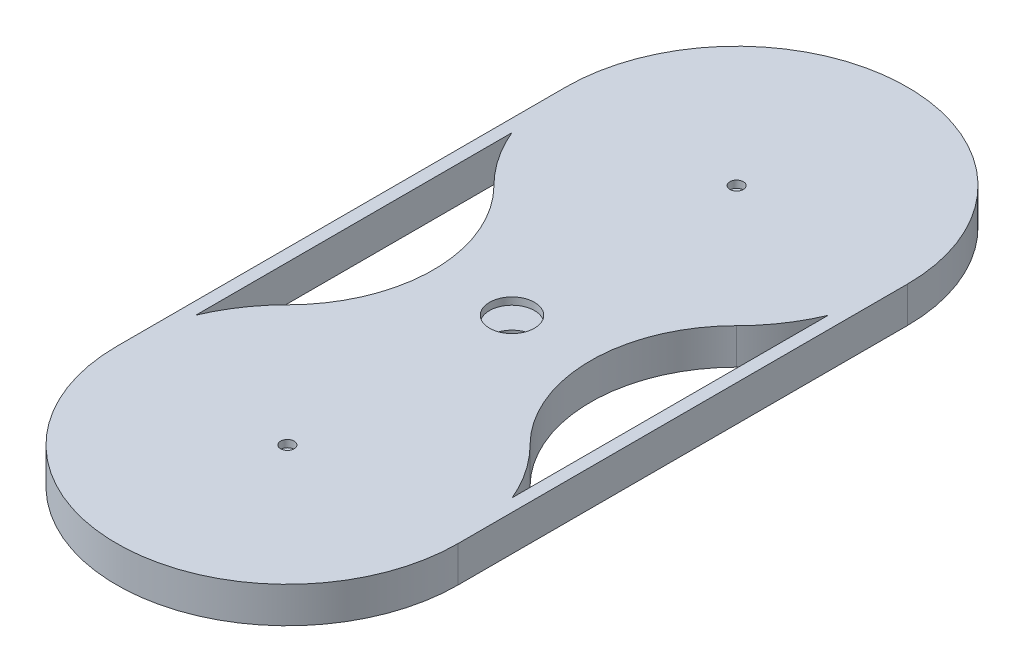
from build123d import *

# Parameters (mm, degrees)
BOSS_EXTRUDE1_DEPTH      = 2
BOSS_EXTRUDE1_DEPTH_BACK = 2
CUT_EXTRUDE1_DEPTH       = 1.2
CUT_EXTRUDE1_DEPTH_BACK  = 1.2
SKETCH4_W                = 7
SKETCH4_H                = 11
BOSS_EXTRUDE2_DEPTH      = 1.2
SWEEP1_PROFILE_R         = 1
SKETCH25_R               = 2.2
CUT_EXTRUDE2_DEPTH       = 2.2
SKETCH26_R               = 2.5
SKETCH26_R_2             = 0.75
CUT_EXTRUDE3_DEPTH       = 10.2
CUT_EXTRUDE4_DEPTH       = 10
CUT_EXTRUDE4_DEPTH_BACK  = 10


with BuildPart() as part:
    # Sketch1 → Boss-Extrude1 (new, two sides: drawn at the far end of the back side and taken through both)
    with BuildSketch(Plane(origin=(0, 0, 0), x_dir=(1, 0, 0), z_dir=(0, 1, 0)).offset(-BOSS_EXTRUDE1_DEPTH_BACK)):
        with BuildLine():
            Line((-19, 0), (-19, -50))
            ThreePointArc((-19, -50), (0, -69), (19, -50))
            Line((19, -50), (19, 0))
            ThreePointArc((19, 0), (0, 19), (-19, 0))
        make_face()
    extrude(amount=BOSS_EXTRUDE1_DEPTH + BOSS_EXTRUDE1_DEPTH_BACK)

    # Sketch3 → Cut-Extrude1 (cut, two sides: drawn at the far end of the back side and taken through both)
    with BuildSketch(Plane(origin=(0, 0, 0), x_dir=(1, 0, 0), z_dir=(0, 1, 0)).offset(-CUT_EXTRUDE1_DEPTH_BACK)):
        with BuildLine():
            ThreePointArc((12.445079349, -37.554920651), (7.244660941, -25), (12.445079349, -12.445079349))
            ThreePointArc((12.445079349, -12.445079349), (16.260279772, -6.73522841), (17.6, 0))
            ThreePointArc((17.6, 0), (0, 17.6), (-17.6, 0))
            ThreePointArc((-17.6, 0), (-16.260279772, -6.73522841), (-12.445079349, -12.445079349))
            ThreePointArc((-12.445079349, -12.445079349), (-7.244660941, -25), (-12.445079349, -37.554920651))
            ThreePointArc((-12.445079349, -37.554920651), (-16.260279772, -43.26477159), (-17.6, -50))
            ThreePointArc((-17.6, -50), (0, -67.6), (17.6, -50))
            ThreePointArc((17.6, -50), (16.260279772, -43.26477159), (12.445079349, -37.554920651))
        make_face()
    extrude(amount=CUT_EXTRUDE1_DEPTH + CUT_EXTRUDE1_DEPTH_BACK, mode=Mode.SUBTRACT)

    # Sketch4 → Boss-Extrude2 (add)
    with BuildSketch(Plane.XZ.offset(2)):
        with Locations((-13.5, 25)):
            Rectangle(SKETCH4_W, SKETCH4_H)
        with Locations((13.5, 25)):
            Rectangle(SKETCH4_W, SKETCH4_H)
    extrude(amount=BOSS_EXTRUDE2_DEPTH)

    # Sweep1: sweep along a path in Sketch6
    with BuildLine(Plane(origin=(-13.5, 0, 0), x_dir=(0, 0, -1), z_dir=(1, 0, 0))) as sweep1_path:
        Line((-22.3, -3.2), (-22.3, -5.3))
        ThreePointArc((-22.3, -5.3), (-24.369122081, -7.65570217), (-26.972043675, -5.907732468))
    # Sweep1 profile (on start of the path) → Sweep1 (sweep)
    with BuildSketch(Plane(origin=(-13.5, -3.2, 22.3), x_dir=(0, 0, -1), z_dir=(0, -1, 0))):
        Circle(SWEEP1_PROFILE_R)
    sweep1 = sweep(path=sweep1_path.line)

    # Mirror1: Sweep1 across plane
    add(sweep1.mirror(Plane(origin=(0, 0, 0), x_dir=(0, 0, 1), z_dir=(1, 0, 0))))

    # Sketch25 → Cut-Extrude2 (cut)
    with BuildSketch(Plane.XZ.offset(2)):
        Circle(SKETCH25_R)
        with Locations((0, 50)):
            Circle(SKETCH25_R)
    extrude(amount=-CUT_EXTRUDE2_DEPTH, mode=Mode.SUBTRACT)

    # Sketch26 → Cut-Extrude3 (cut)
    with BuildSketch(Plane(origin=(0, -2, 0), x_dir=(-1, 0, 0), z_dir=(0, -1, 0))):
        with Locations((0, -25)):
            Circle(SKETCH26_R)
        with Locations((0, -50)):
            Circle(SKETCH26_R_2)
        Circle(SKETCH26_R_2)
    extrude(amount=-CUT_EXTRUDE3_DEPTH, mode=Mode.SUBTRACT)

    # Sketch27 → Cut-Extrude4 (cut, two sides: drawn at the far end of the back side and taken through both)
    with BuildSketch(Plane.XZ.offset(2).offset(-CUT_EXTRUDE4_DEPTH_BACK)):
        with BuildLine():
            Line((-17.6, 7.419568721), (-17.6, 42.580431279))
            ThreePointArc((-17.6, 42.580431279), (-15.847779861, 39.33895533), (-13.505739521, 36.494260479))
            ThreePointArc((-13.505739521, 36.494260479), (-8.744660941, 25), (-13.505739521, 13.505739521))
            ThreePointArc((-13.505739521, 13.505739521), (-15.847779861, 10.66104467), (-17.6, 7.419568721))
        make_face()
        with BuildLine():
            Line((17.6, 42.580431279), (17.6, 7.419568721))
            ThreePointArc((17.6, 7.419568721), (15.847779861, 10.66104467), (13.505739521, 13.505739521))
            ThreePointArc((13.505739521, 13.505739521), (8.744660941, 25), (13.505739521, 36.494260479))
            ThreePointArc((13.505739521, 36.494260479), (15.847779861, 39.33895533), (17.6, 42.580431279))
        make_face()
    extrude(amount=CUT_EXTRUDE4_DEPTH + CUT_EXTRUDE4_DEPTH_BACK, mode=Mode.SUBTRACT)


solid = part.part
